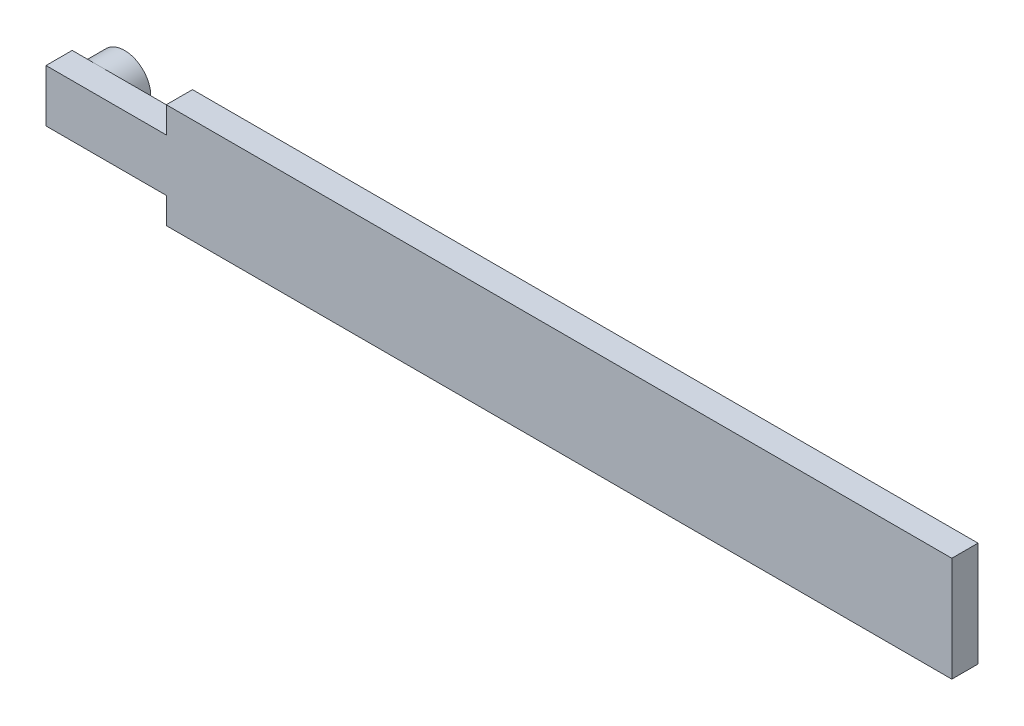
from build123d import *

# Parameters (mm, degrees)
BOSS_EXTRUDE1_DEPTH = 5
SKETCH2_R           = 5
BOSS_EXTRUDE2_DEPTH = 5


with BuildPart() as part:
    # Sketch1 → Boss-Extrude1 (new body)
    with BuildSketch(Plane.XY):
        Polygon((-75, -10), (75, -10), (75, 10), (-75, 10), (-75, 5), (-97.970130586, 5), (-97.970130586, -5), (-75, -5), align=None)
    extrude(amount=BOSS_EXTRUDE1_DEPTH)

    # Sketch2 → Boss-Extrude2 (add)
    with BuildSketch(Plane(origin=(0, 0, 0), x_dir=(-1, 0, 0), z_dir=(0, 0, -1))):
        with Locations((92.970130586, 0)):
            Circle(SKETCH2_R)
    extrude(amount=BOSS_EXTRUDE2_DEPTH)


solid = part.part
